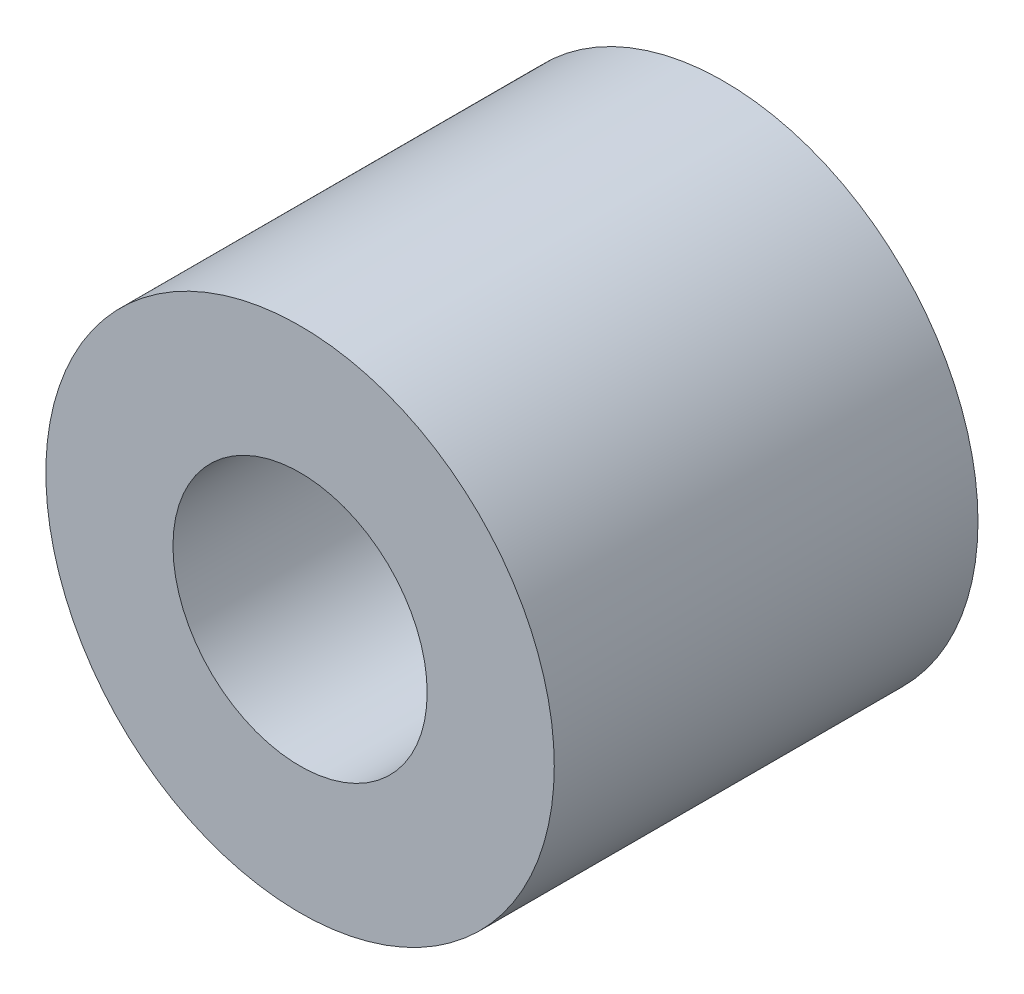
from build123d import *

# Parameters (mm, degrees)
SKETCH1_R      = 3
SKETCH1_R_2    = 1.5
EXTRUDE1_DEPTH = 5


with BuildPart() as part:
    # Sketch1 → Extrude1 (new body)
    with BuildSketch(Plane.XY):
        Circle(SKETCH1_R)
        Circle(SKETCH1_R_2, mode=Mode.SUBTRACT)
    extrude(amount=EXTRUDE1_DEPTH)


solid = part.part
